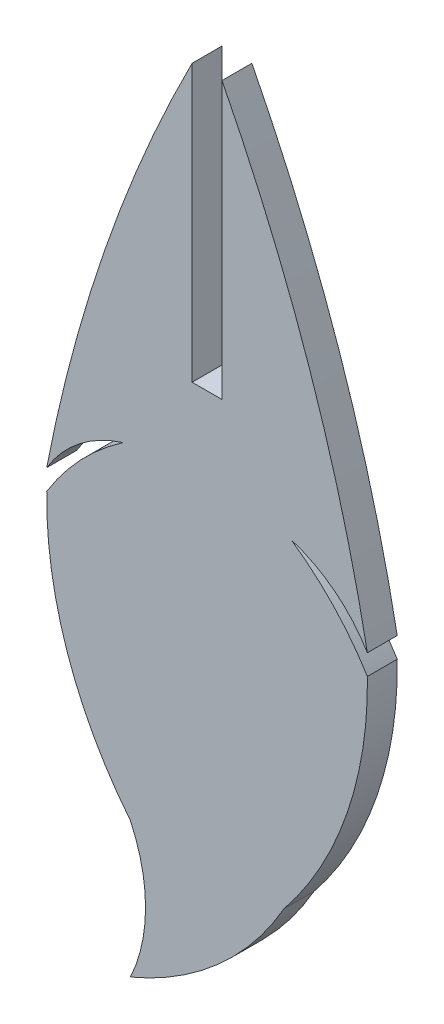
from build123d import *

# Parameters (mm, degrees)
BOSS_EXTRUDE1_DEPTH = 1.524


with BuildPart() as part:
    # Sketch1 → Boss-Extrude1 (new body)
    with BuildSketch(Plane.XY):
        with BuildLine():
            Line((-1.524, -34.676201819), (0, -34.676201819))
            Line((0, -34.676201819), (0, -20.584065252))
            ThreePointArc((0, -20.584065252), (4.472947003, -31.108201588), (7.416031026, -42.158222264))
            ThreePointArc((7.416031026, -42.158222264), (5.753516475, -40.272714916), (3.52711699, -39.105565432))
            ThreePointArc((3.52711699, -39.105565432), (5.686055365, -40.951036914), (7.416031026, -43.203583054))
            ThreePointArc((7.416031026, -43.203583054), (6.372439306, -49.781793421), (3.150525994, -55.611133859))
            ThreePointArc((3.150525994, -55.611133859), (-0.189129191, -59.717886603), (-4.674525994, -62.528568082))
            ThreePointArc((-4.674525994, -62.528568082), (-3.899739777, -59.06985097), (-4.674525994, -55.611133859))
            ThreePointArc((-4.674525994, -55.611133859), (-7.896439306, -49.781793421), (-8.940031026, -43.203583054))
            ThreePointArc((-8.940031026, -43.203583054), (-7.210055365, -40.951036914), (-5.05111699, -39.105565432))
            ThreePointArc((-5.05111699, -39.105565432), (-7.277516475, -40.272714916), (-8.940031026, -42.158222264))
            ThreePointArc((-8.940031026, -42.158222264), (-5.996947003, -31.108201588), (-1.524, -20.584065252))
            Line((-1.524, -20.584065252), (-1.524, -34.676201819))
        make_face()
    extrude(amount=BOSS_EXTRUDE1_DEPTH)


solid = part.part
